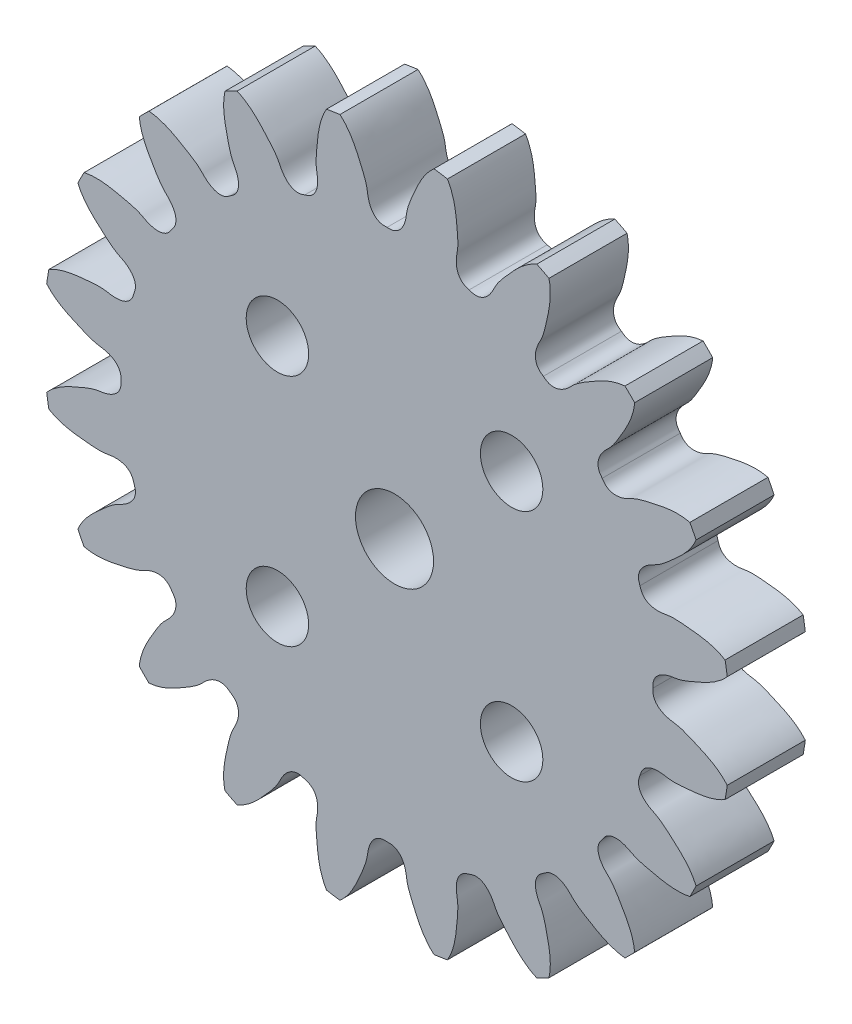
from build123d import *

# Parameters (mm, degrees)
SKETCH1_R           = 22
BOSS_EXTRUDE1_DEPTH = 5
SKETCH2_R           = 2
CUT_EXTRUDE1_DEPTH  = 30
SKETCH3_R           = 4
BOSS_EXTRUDE3_DEPTH = 9
SKETCH4_R           = 2.5
CUT_EXTRUDE2_DEPTH  = 16
CUT_EXTRUDE3_DEPTH  = 10
CIRPATTERN1_COUNT   = 20


with BuildPart() as part:
    # Sketch1 → Boss-Extrude1 (new body)
    with BuildSketch(Plane.XY):
        with Locations((-0.483808042, 0)):
            Circle(SKETCH1_R)
    extrude(amount=BOSS_EXTRUDE1_DEPTH)

    # Sketch2 → Cut-Extrude1 (cut)
    with BuildSketch(Plane(origin=(0, 0, 0), x_dir=(-1, 0, 0), z_dir=(0, 0, -1))):
        with Locations((7.5, 7.5)):
            Circle(SKETCH2_R)
        with Locations((7.5, -7.5)):
            Circle(SKETCH2_R)
        with Locations((-7.5, -7.5)):
            Circle(SKETCH2_R)
        with Locations((-7.5, 7.5)):
            Circle(SKETCH2_R)
    extrude(amount=-CUT_EXTRUDE1_DEPTH, mode=Mode.SUBTRACT)

    # Sketch3 → Boss-Extrude3 (add)
    with BuildSketch(Plane(origin=(0, 0, 0), x_dir=(-1, 0, 0), z_dir=(0, 0, -1))):
        Circle(SKETCH3_R)
    extrude(amount=BOSS_EXTRUDE3_DEPTH)

    # Sketch4 → Cut-Extrude2 (cut)
    with BuildSketch(Plane(origin=(0, 0, -9), x_dir=(-1, 0, 0), z_dir=(0, 0, -1))):
        Circle(SKETCH4_R)
    extrude(amount=-CUT_EXTRUDE2_DEPTH, mode=Mode.SUBTRACT)

    # Sketch6 → Cut-Extrude3 (cut)
    with BuildSketch(Plane(origin=(0, 0, 0), x_dir=(-1, 0, 0), z_dir=(0, 0, -1))):
        with BuildLine():
            ThreePointArc((22.31938586, -3.058932556), (22.467883289, -1.532778045), (22.510198081, 0))
            ThreePointArc((22.510198081, 0), (22.467883289, 1.532778045), (22.31938586, 3.058932556))
            add(Edge.make_bspline(
                [(17.520937668, 0), (17.520767791, 0.027325523), (17.521964375, 0.086047993), (17.520200716, 0.161403358), (17.522732209, 0.232513889), (17.528571601, 0.29487591), (17.54088759, 0.362214433), (17.55823467, 0.427242398), (17.58018391, 0.489425719), (17.606131312, 0.548411274), (17.635510495, 0.604006421), (17.66778726, 0.65615851), (17.702494128, 0.704923432), (17.739238379, 0.750434125), (17.777703938, 0.792871968), (17.817645855, 0.832443474), (17.858881479, 0.869362746), (17.901280224, 0.903839254), (17.94475347, 0.936070008), (17.989245378, 0.966235103), (18.034725021, 0.994495672), (18.081179879, 1.020993482), (18.128610649, 1.045851556), (18.177027174, 1.069175405), (18.226445334, 1.091054555), (18.276884696, 1.11156419), (18.32836678, 1.13076677), (18.38091379, 1.148713574), (18.434547715, 1.165446076), (18.489289685, 1.180997348), (18.545159599, 1.195392671), (18.602175641, 1.208652481), (18.660354922, 1.220785793), (18.719710318, 1.231819343), (18.780262199, 1.241689744), (18.841993493, 1.250658953), (18.981219765, 1.266272533), (19.405815651, 1.347799972), (20.610006081, 1.861199446), (21.72044134, 2.343273093), (22.31938586, 3.058932556)],
                knots=[0.490533153, 0.490533153, 0.490533153, 0.490533153, 0.497479783, 0.505458547, 0.509686103, 0.515560903, 0.521362411, 0.527065364, 0.532651015, 0.538107728, 0.543430769, 0.548621513, 0.553686318, 0.558635283, 0.563481071, 0.568237884, 0.572920635, 0.577544329, 0.582123616, 0.586672492, 0.591204124, 0.595730757, 0.600263675, 0.604813219, 0.60938882, 0.613999051, 0.618651691, 0.623353788, 0.628111722, 0.632931272, 0.637817669, 0.642775655, 0.647809528, 0.652923191, 0.658120189, 0.66340375, 0.668776812, 0.693732617, 0.772916112, 1, 1, 1, 1], degree=3))
            add(Edge.make_bspline(
                [(17.520937668, 0), (17.520767791, -0.027325523), (17.521964375, -0.086047993), (17.520200716, -0.161403358), (17.522732209, -0.232513889), (17.528571601, -0.29487591), (17.54088759, -0.362214433), (17.55823467, -0.427242398), (17.58018391, -0.489425719), (17.606131312, -0.548411274), (17.635510495, -0.604006421), (17.66778726, -0.65615851), (17.702494128, -0.704923432), (17.739238379, -0.750434126), (17.777703938, -0.792871968), (17.817645855, -0.832443474), (17.858881479, -0.869362746), (17.901280224, -0.903839254), (17.94475347, -0.936070008), (17.989245378, -0.966235103), (18.034725021, -0.994495672), (18.081179879, -1.020993482), (18.128610649, -1.045851556), (18.177027174, -1.069175405), (18.226445334, -1.091054555), (18.276884696, -1.11156419), (18.32836678, -1.13076677), (18.38091379, -1.148713574), (18.434547715, -1.165446076), (18.489289685, -1.180997348), (18.545159599, -1.195392671), (18.602175641, -1.208652481), (18.660354922, -1.220785793), (18.719710318, -1.231819344), (18.780262199, -1.241689744), (18.841993493, -1.250658953), (18.981219765, -1.266272533), (19.405815651, -1.347799972), (20.610006081, -1.861199446), (21.72044134, -2.343273093), (22.31938586, -3.058932556)],
                knots=[0.490533153, 0.490533153, 0.490533153, 0.490533153, 0.497479783, 0.505458547, 0.509686103, 0.515560903, 0.521362411, 0.527065364, 0.532651015, 0.538107728, 0.543430769, 0.548621513, 0.553686318, 0.558635283, 0.563481071, 0.568237884, 0.572920635, 0.577544329, 0.582123616, 0.586672492, 0.591204124, 0.595730757, 0.600263675, 0.604813219, 0.60938882, 0.613999051, 0.618651691, 0.623353788, 0.628111722, 0.632931272, 0.637817669, 0.642775655, 0.647809528, 0.652923191, 0.658120189, 0.66340375, 0.668776812, 0.693732617, 0.772916112, 1, 1, 1, 1], degree=3))
        make_face()
    cut_extrude3 = extrude(amount=-CUT_EXTRUDE3_DEPTH, mode=Mode.SUBTRACT)

    # CirPattern1: Cut-Extrude3 ×20 about axis
    cirpattern1_axis = Axis((-0.483808042, 0, 0), (0, 0, 1))
    for i in range(1, CIRPATTERN1_COUNT):
        add(cut_extrude3.rotate(cirpattern1_axis, i * 360 / CIRPATTERN1_COUNT), mode=Mode.SUBTRACT)


solid = part.part
